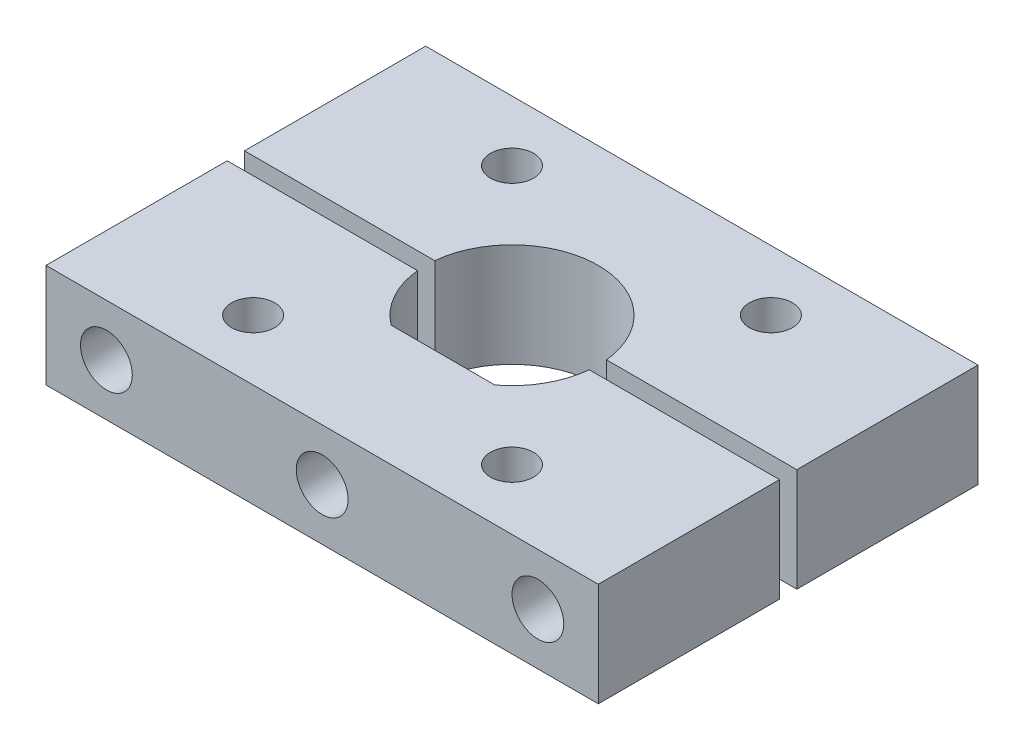
from build123d import *

# Parameters (mm, degrees)
EXTRUDE_1_DEPTH             = 3
EXTRUDE_1_2_DEPTH           = 3
SKETCH_3_W                  = 1.25
SKETCH_3_H                  = 22
HOLE_WIZARD_M3_1_AT_2_COUNT = 2
HOLE_WIZARD_M3_1_AT_2_PITCH = 25
SKETCH_5_W                  = 1.25
SKETCH_5_H                  = 6
HOLE_WIZARD_M3_2_AT_2_COUNT = 2
HOLE_WIZARD_M3_2_AT_2_PITCH = 15
HOLE_WIZARD_M3_2_AT_3_COUNT = 2
HOLE_WIZARD_M3_2_AT_3_PITCH = 15
HOLE_WIZARD_M3_2_AT_4_COUNT = 2
HOLE_WIZARD_M3_2_AT_4_PITCH = 21.213203436
SKETCH_6_R                  = 1.5
CUT_EXTRUDE_1_DEPTH         = 23


with BuildPart() as part:
    # 草图1 → 凸台-拉伸1 (new body, symmetric)
    with BuildSketch(Plane(origin=(0, 0, 0), x_dir=(1, 0, 0), z_dir=(0, 1, 0))):
        with BuildLine():
            Line((-3, -4), (3, -4))
            ThreePointArc((3, -4), (4.354584455, -2.457151648), (4.974937186, -0.5))
            Line((4.974937186, -0.5), (16, -0.5))
            Line((16, -0.5), (16, -11))
            Line((16, -11), (-16, -11))
            Line((-16, -11), (-16, -0.5))
            Line((-16, -0.5), (-4.974937186, -0.5))
            ThreePointArc((-4.974937186, -0.5), (-4.354584455, -2.457151648), (-3, -4))
        make_face()
    extrude(amount=EXTRUDE_1_DEPTH, both=True)


with BuildPart() as body_2:
    # 草图1 → Extrude 1 2 (new body, symmetric)
    with BuildSketch(Plane(origin=(0, 0, 0), x_dir=(1, 0, 0), z_dir=(0, 1, 0))):
        with BuildLine():
            Line((-16, 11), (16, 11))
            Line((16, 11), (16, 0.5))
            Line((16, 0.5), (4.974937186, 0.5))
            ThreePointArc((4.974937186, 0.5), (0, 5), (-4.974937186, 0.5))
            Line((-4.974937186, 0.5), (-16, 0.5))
            Line((-16, 0.5), (-16, 11))
        make_face()
    extrude(amount=EXTRUDE_1_2_DEPTH, both=True)


with BuildPart() as hole_wizard_m3_1_tool:
    # 草图3 → M3 螺纹孔1 (revolve)
    with BuildSketch(Plane(origin=(-12.5, 0, 11), x_dir=(0, -1, 0), z_dir=(1, 0, 0))):
        with Locations((0.625, 11)):
            Rectangle(SKETCH_3_W, SKETCH_3_H)
    hole_wizard_m3_1 = revolve(axis=Axis((-12.5, 0, 17.35), (0, 0, -1)))


with BuildPart() as part_1:
    add(part.part)

    # M3 螺纹孔1: cut by hole_wizard_m3_1_tool
    add(hole_wizard_m3_1_tool.part, mode=Mode.SUBTRACT)


with BuildPart() as body_2_1:
    add(body_2.part)

    # M3 螺纹孔1: cut by hole_wizard_m3_1_tool
    add(hole_wizard_m3_1_tool.part, mode=Mode.SUBTRACT)


with BuildPart() as hole_wizard_m3_1_at_2_tool:
    # M3 螺纹孔1 at 2: M3 螺纹孔1 ×2
    with Locations(*[(i * HOLE_WIZARD_M3_1_AT_2_PITCH, 0, 0) for i in range(1, HOLE_WIZARD_M3_1_AT_2_COUNT)]):
        add(hole_wizard_m3_1)


with BuildPart() as part_2:
    add(part_1.part)

    # M3 螺纹孔1 at 2: cut by hole_wizard_m3_1_at_2_tool
    add(hole_wizard_m3_1_at_2_tool.part, mode=Mode.SUBTRACT)


with BuildPart() as body_2_2:
    add(body_2_1.part)

    # M3 螺纹孔1 at 2: cut by hole_wizard_m3_1_at_2_tool
    add(hole_wizard_m3_1_at_2_tool.part, mode=Mode.SUBTRACT)

    # 草图5 → M3 螺纹孔2 (revolve, cut)
    with BuildSketch(Plane(origin=(-7.5, 3, -7.5), x_dir=(0, 0, 1), z_dir=(1, 0, 0))):
        with Locations((0.625, 3)):
            Rectangle(SKETCH_5_W, SKETCH_5_H)
    hole_wizard_m3_2 = revolve(axis=Axis((-7.5, 9.35, -7.5), (0, -1, 0)), mode=Mode.SUBTRACT)

    # M3 螺纹孔2 at 2: M3 螺纹孔2 ×2
    with Locations(*[(i * HOLE_WIZARD_M3_2_AT_2_PITCH, 0, 0) for i in range(1, HOLE_WIZARD_M3_2_AT_2_COUNT)]):
        add(hole_wizard_m3_2, mode=Mode.SUBTRACT)


with BuildPart() as part_3:
    add(part_2.part)

    # M3 螺纹孔2 at 3: M3 螺纹孔2 ×2
    with Locations(*[(0, 0, i * HOLE_WIZARD_M3_2_AT_3_PITCH) for i in range(1, HOLE_WIZARD_M3_2_AT_3_COUNT)]):
        add(hole_wizard_m3_2, mode=Mode.SUBTRACT)

    # M3 螺纹孔2 at 4: M3 螺纹孔2 ×2
    with Locations(*[Vector(0.707106781, 0, 0.707106781) * (i * HOLE_WIZARD_M3_2_AT_4_PITCH) for i in range(1, HOLE_WIZARD_M3_2_AT_4_COUNT)]):
        add(hole_wizard_m3_2, mode=Mode.SUBTRACT)

    # 草图6 → 切除-拉伸1 (cut, through all)
    with BuildSketch(Plane.XY.offset(11)):
        Circle(SKETCH_6_R)
        with Locations((-12.5, 0)):
            Circle(SKETCH_6_R)
        with Locations((12.5, 0)):
            Circle(SKETCH_6_R)
    extrude(amount=-CUT_EXTRUDE_1_DEPTH, mode=Mode.SUBTRACT)


solid = Compound([body_2_2.part, part_3.part])
